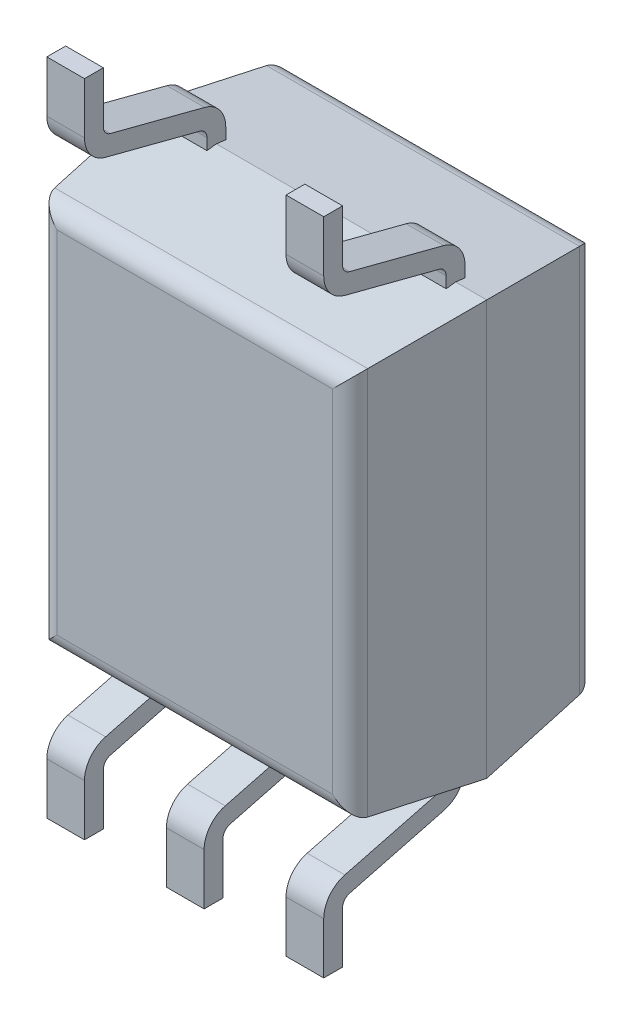
from build123d import *

# Parameters (mm, degrees)
SKETCH1_W                = 3.6
SKETCH1_H                = 4.4
EXTRUDE1_DEPTH           = 1.3
EXTRUDE1_TAPER           = 7
EXTRUDE1_OTHER_WAY_DEPTH = 1.3
EXTRUDE1_OTHER_WAY_TAPER = 7
FILLET1_R                = 0.2
SKETCH3_W                = 0.4
SKETCH3_H                = 0.2
SKETCH7_R                = 0.3
EXTRUDE2_DEPTH           = 0.1
SKETCH5_W                = 0.4
SKETCH5_H                = 0.2


with BuildPart() as part:
    # Sketch1 → Extrude1 (new body)
    with BuildSketch(Plane.XY):
        Rectangle(SKETCH1_W, SKETCH1_H)
    extrude(amount=EXTRUDE1_DEPTH, taper=EXTRUDE1_TAPER)

    # Sketch1 → Extrude1 other way (add)
    with BuildSketch(Plane.XY):
        Rectangle(SKETCH1_W, SKETCH1_H)
    extrude(amount=-EXTRUDE1_OTHER_WAY_DEPTH, taper=EXTRUDE1_OTHER_WAY_TAPER)

    # Fillet1
    fillet1_edges = [part.edges().sort_by_distance(p)[0] for p in [
        (-1.640380071, 0, -1.3),
        (0, -2.040380071, -1.3),
        (1.640380071, 0, 1.3),
        (0, 2.040380071, 1.3),
        (-1.640380071, 0, 1.3),
        (0, -2.040380071, 1.3),
        (1.640380071, 0, -1.3),
        (0, 2.040380071, -1.3),
    ]]
    fillet(fillet1_edges, radius=FILLET1_R)

    # Sweep4: sweep along a path in Sketch4
    with BuildLine(Plane(origin=(0, 0, 0), x_dir=(0, 0, -1), z_dir=(1, 0, 0))) as sweep4_path:
        Line((0, 2.061944248), (0, 2.307301205))
        ThreePointArc((0, 2.307301205), (-0.04178036, 2.429639038), (-0.149665454, 2.500863685))
        Line((-0.149665454, 2.500863685), (-1.150334546, 2.761080563))
        ThreePointArc((-1.150334546, 2.761080563), (-1.25821964, 2.83230521), (-1.3, 2.954643043))
        Line((-1.3, 2.954643043), (-1.3, 3.5))
    # Sketch3 → Sweep4 (sweep)
    with BuildSketch(Plane(origin=(0, 2.061944248, 0), x_dir=(-1, 0, 0), z_dir=(0, 1, 0))):
        with Locations((1.27, 0)):
            Rectangle(SKETCH3_W, SKETCH3_H)
        with Locations((-1.27, 0)):
            Rectangle(SKETCH3_W, SKETCH3_H)
    sweep(path=sweep4_path.line)

    # Sketch7 → Extrude2 (cut)
    with BuildSketch(Plane(origin=(0, 0, -1.3), x_dir=(-1, 0, 0), z_dir=(0, 0, -1))):
        with Locations((1.02, 1.4)):
            Circle(SKETCH7_R)
    extrude(amount=-EXTRUDE2_DEPTH, mode=Mode.SUBTRACT)

    # Sweep3: sweep along a path in Sketch8
    with BuildLine(Plane(origin=(0, 0, 0), x_dir=(0, 0, -1), z_dir=(1, 0, 0))) as sweep3_path:
        Line((-1.3, -3.5), (-1.3, -2.954643043))
        ThreePointArc((-1.3, -2.954643043), (-1.25821964, -2.83230521), (-1.150334546, -2.761080563))
        Line((-1.150334546, -2.761080563), (-0.149665454, -2.500863685))
        ThreePointArc((-0.149665454, -2.500863685), (-0.04178036, -2.429639038), (0, -2.307301205))
        Line((0, -2.307301205), (0, -2.061944248))
    # Sketch5 → Sweep3 (sweep)
    with BuildSketch(Plane(origin=(0, -2.061944248, 0), x_dir=(-1, 0, 0), z_dir=(0, 1, 0))):
        with Locations((1.27, 0)):
            Rectangle(SKETCH5_W, SKETCH5_H)
        Rectangle(SKETCH5_W, SKETCH5_H)
        with Locations((-1.27, 0)):
            Rectangle(SKETCH5_W, SKETCH5_H)
    sweep(path=sweep3_path.line)


solid = part.part
